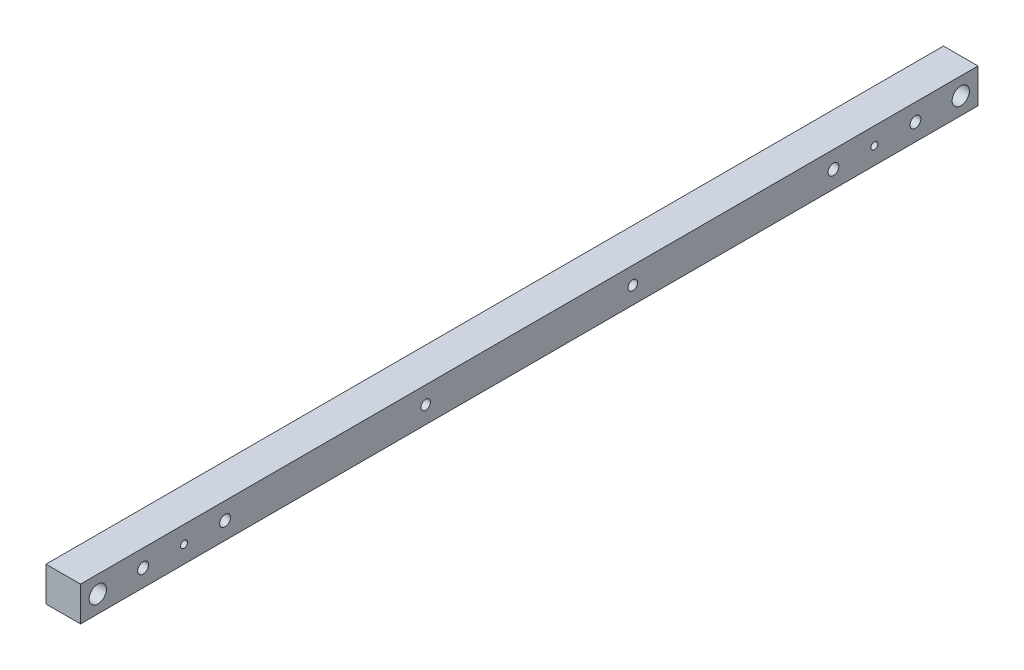
from build123d import *

# Parameters (mm, degrees)
SKETCH1_W               = 25.4
SKETCH1_H               = 25.4
BOSS_EXTRUDE1_DEPTH     = 660.4
SKETCH2_R               = 6.35
CUT_EXTRUDE4_DEPTH      = 26.4
CUT_EXTRUDE4_DEPTH_BACK = 1
SKETCH3_R               = 3.97
SKETCH3_R_2             = 2.55
CUT_EXTRUDE5_DEPTH      = 26.4
SKETCH10_R              = 3.5
CUT_EXTRUDE6_DEPTH      = 26.4


with BuildPart() as part:
    # Sketch1 → Boss-Extrude1 (new body)
    with BuildSketch(Plane.XY):
        Rectangle(SKETCH1_W, SKETCH1_H)
    extrude(amount=BOSS_EXTRUDE1_DEPTH)

    # Sketch2 → Cut-Extrude4 (cut, two sides)
    with BuildSketch(Plane(origin=(-12.7, 0, 0), x_dir=(0, 0, -1), z_dir=(1, 0, 0))) as cut_extrude4_sk:
        with Locations((-12.7, 0)):
            Circle(SKETCH2_R)
        with Locations((-647.7, 0)):
            Circle(SKETCH2_R)
    extrude(amount=CUT_EXTRUDE4_DEPTH, mode=Mode.SUBTRACT)
    extrude(cut_extrude4_sk.sketch, amount=-CUT_EXTRUDE4_DEPTH_BACK, mode=Mode.SUBTRACT)

    # Sketch3 → Cut-Extrude5 (cut, through all)
    with BuildSketch(Plane.ZY.offset(12.7)):
        with Locations((554.0375, 0)):
            Circle(SKETCH3_R)
        with Locations((106.3625, 0)):
            Circle(SKETCH3_R)
        with Locations((614.3625, 0)):
            Circle(SKETCH3_R)
        with Locations((584.2, 0)):
            Circle(SKETCH3_R_2)
        with Locations((46.0375, 0)):
            Circle(SKETCH3_R)
        with Locations((76.2, 0)):
            Circle(SKETCH3_R_2)
    extrude(amount=-CUT_EXTRUDE5_DEPTH, mode=Mode.SUBTRACT)

    # Sketch10 → Cut-Extrude6 (cut, through all)
    with BuildSketch(Plane.ZY.offset(12.7)):
        with Locations((406.4, 0)):
            Circle(SKETCH10_R)
        with Locations((254, 0)):
            Circle(SKETCH10_R)
    extrude(amount=-CUT_EXTRUDE6_DEPTH, mode=Mode.SUBTRACT)


solid = part.part
